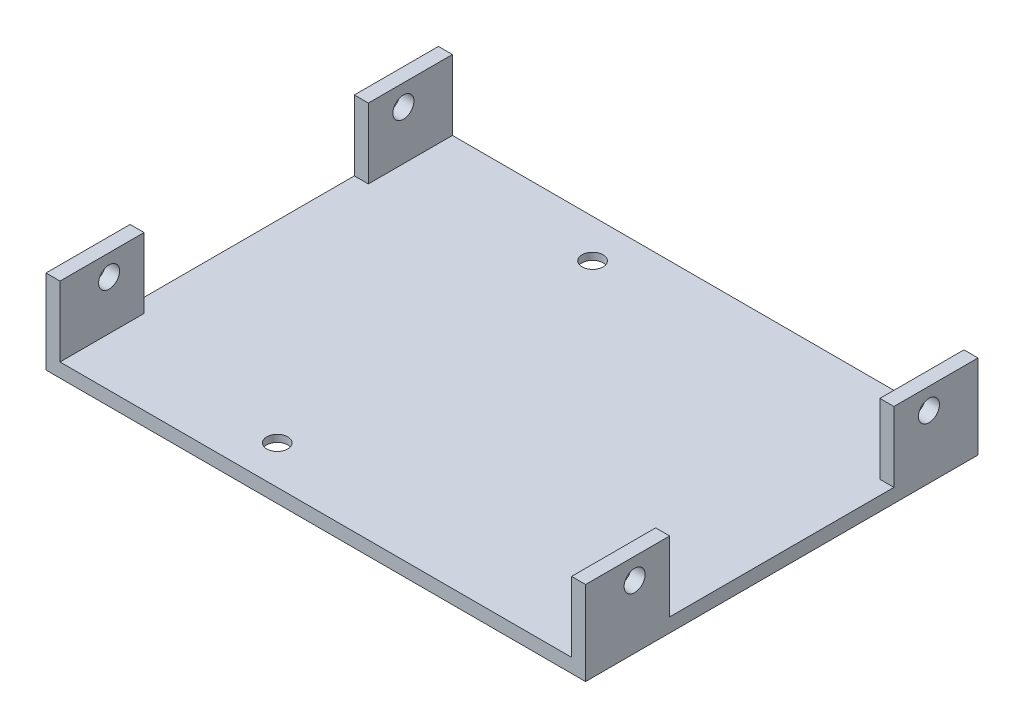
from build123d import *

# Parameters (mm, degrees)
SKETCH1_W           = 77
SKETCH1_H           = 56
BOSS_EXTRUDE1_DEPTH = 2
SKETCH2_R           = 1.5
CUT_EXTRUDE1_DEPTH  = 3
SKETCH3_W           = 2
SKETCH3_H           = 12
BOSS_EXTRUDE2_DEPTH = 10
SKETCH4_R           = 1.5
CUT_EXTRUDE2_DEPTH  = 78
SKETCH5_R           = 3.25
CUT_EXTRUDE3_DEPTH  = 1


with BuildPart() as part:
    # Sketch1 → Boss-Extrude1 (new body)
    with BuildSketch(Plane(origin=(0, 0, 0), x_dir=(1, 0, 0), z_dir=(0, 1, 0))):
        with Locations((-3.12052506, -6.090692124)):
            Rectangle(SKETCH1_W, SKETCH1_H)
    extrude(amount=BOSS_EXTRUDE1_DEPTH)

    # Sketch2 → Cut-Extrude1 (cut, through all)
    with BuildSketch(Plane(origin=(0, 2, 0), x_dir=(1, 0, 0), z_dir=(0, 1, 0))):
        with Locations((30.87947494, 16.409307876)):
            Circle(SKETCH2_R)
        with Locations((30.87947494, -28.590692124)):
            Circle(SKETCH2_R)
        with Locations((-14.12052506, 16.409307876)):
            Circle(SKETCH2_R)
        with Locations((-14.12052506, -28.590692124)):
            Circle(SKETCH2_R)
    extrude(amount=-CUT_EXTRUDE1_DEPTH, mode=Mode.SUBTRACT)

    # Sketch3 → Boss-Extrude2 (add)
    with BuildSketch(Plane(origin=(0, 2, 0), x_dir=(1, 0, 0), z_dir=(0, 1, 0))):
        with Locations((34.37947494, 15.909307876)):
            Rectangle(SKETCH3_W, SKETCH3_H)
        with Locations((34.37947494, -28.090692124)):
            Rectangle(SKETCH3_W, SKETCH3_H)
        with Locations((-40.62052506, 15.909307876)):
            Rectangle(SKETCH3_W, SKETCH3_H)
        with Locations((-40.62052506, -28.090692124)):
            Rectangle(SKETCH3_W, SKETCH3_H)
    extrude(amount=BOSS_EXTRUDE2_DEPTH)

    # Sketch4 → Cut-Extrude2 (cut, through all)
    with BuildSketch(Plane(origin=(35.37947494, 0, 0), x_dir=(0, 0, -1), z_dir=(1, 0, 0))):
        with Locations((-27.090692124, 9)):
            Circle(SKETCH4_R)
        with Locations((14.909307876, 9)):
            Circle(SKETCH4_R)
    extrude(amount=-CUT_EXTRUDE2_DEPTH, mode=Mode.SUBTRACT)

    # Sketch5 → Cut-Extrude3 (cut)
    with BuildSketch(Plane(origin=(0, 0, 0), x_dir=(-1, 0, 0), z_dir=(0, -1, 0))):
        with Locations((14.12052506, -28.590692124)):
            Circle(SKETCH5_R)
        with Locations((-30.87947494, -28.590692124)):
            Circle(SKETCH5_R)
        with Locations((-30.87947494, 16.409307876)):
            Circle(SKETCH5_R)
        with Locations((14.12052506, 16.409307876)):
            Circle(SKETCH5_R)
    extrude(amount=-CUT_EXTRUDE3_DEPTH, mode=Mode.SUBTRACT)


solid = part.part
